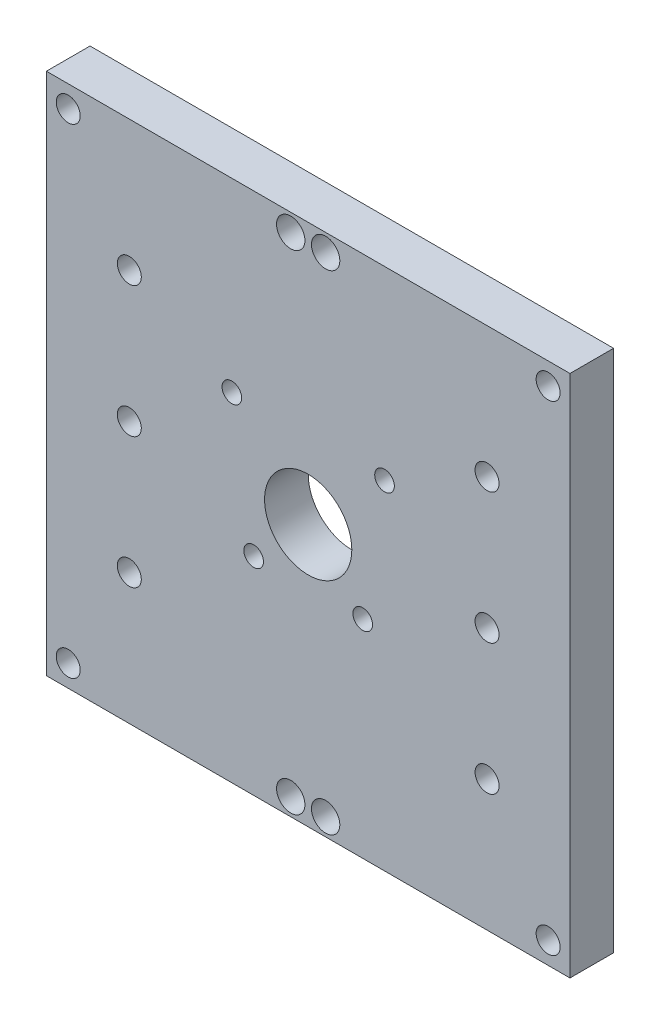
from build123d import *

# Parameters (mm, degrees)
SKETCH1_W           = 120
SKETCH1_H           = 10
BOSS_EXTRUDE1_DEPTH = 120
SKETCH2_R           = 2.25
SKETCH2_R_2         = 2.75
SKETCH2_R_3         = 10
SKETCH2_R_4         = 3.25
CUT_EXTRUDE1_DEPTH  = 10


with BuildPart() as part:
    # Sketch1 → Boss-Extrude1 (new body)
    with BuildSketch(Plane(origin=(0, 0, 0), x_dir=(1, 0, 0), z_dir=(0, 1, 0))):
        Rectangle(SKETCH1_W, SKETCH1_H)
    extrude(amount=BOSS_EXTRUDE1_DEPTH)

    # Sketch2 → Cut-Extrude1 (cut)
    with BuildSketch(Plane.XY.offset(5)):
        with Locations((-17.5, 77.5)):
            Circle(SKETCH2_R)
        with Locations((-12.5, 47.5)):
            Circle(SKETCH2_R)
        with Locations((12.5, 47.5)):
            Circle(SKETCH2_R)
        with Locations((17.5, 77.5)):
            Circle(SKETCH2_R)
        with Locations((55, 5)):
            Circle(SKETCH2_R_2)
        with Locations((55, 115)):
            Circle(SKETCH2_R_2)
        with Locations((0, 60)):
            Circle(SKETCH2_R_3)
        with Locations((-41, 90)):
            Circle(SKETCH2_R_2)
        with Locations((-41, 60)):
            Circle(SKETCH2_R_2)
        with Locations((-41, 30)):
            Circle(SKETCH2_R_2)
        with Locations((41, 30)):
            Circle(SKETCH2_R_2)
        with Locations((41, 60)):
            Circle(SKETCH2_R_2)
        with Locations((-4, 116)):
            Circle(SKETCH2_R_4)
        with Locations((4, 116)):
            Circle(SKETCH2_R_4)
        with Locations((41, 90)):
            Circle(SKETCH2_R_2)
        with Locations((-4, 4)):
            Circle(SKETCH2_R_4)
        with Locations((4, 4)):
            Circle(SKETCH2_R_4)
        with Locations((-55, 5)):
            Circle(SKETCH2_R_2)
        with Locations((-55, 115)):
            Circle(SKETCH2_R_2)
    extrude(amount=-CUT_EXTRUDE1_DEPTH, mode=Mode.SUBTRACT)


solid = part.part
